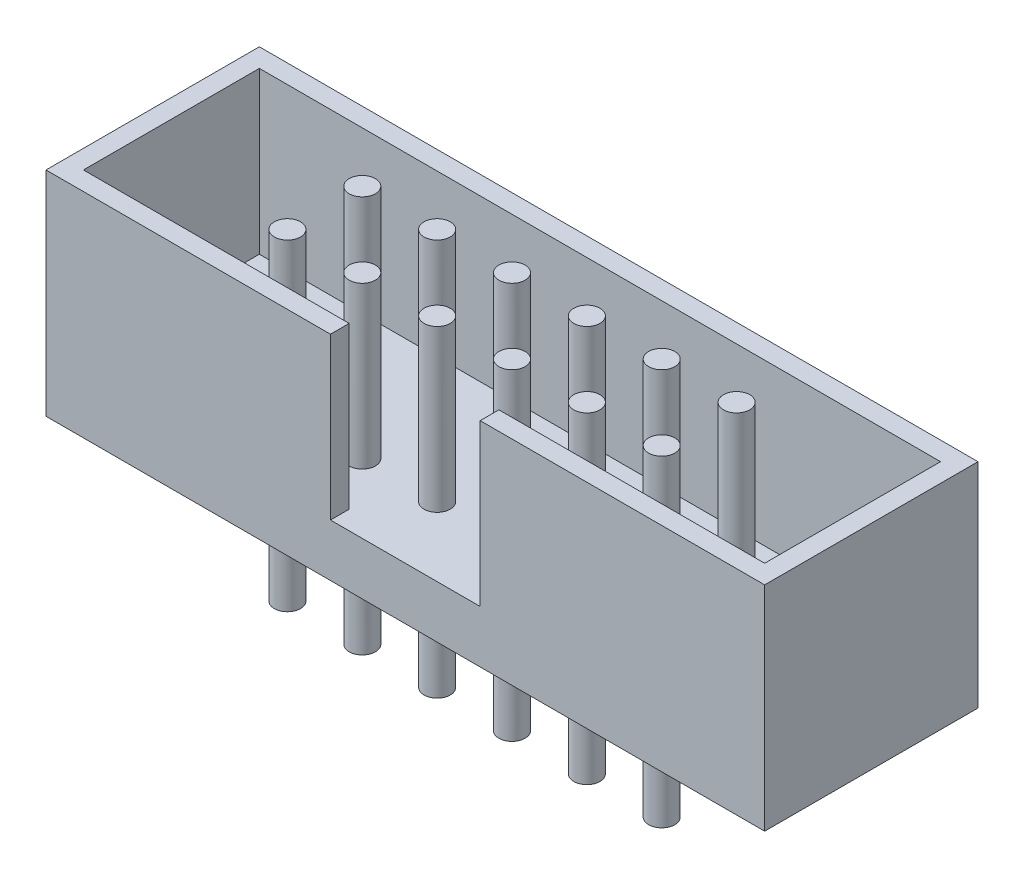
from build123d import *

# Parameters (mm, degrees)
SKETCH_1_W                  = 19.2
SKETCH_1_H                  = 5.7
EXTRUDE_1_DEPTH             = 5.7
SKETCH_2_W                  = 18.2
SKETCH_2_H                  = 4.7
CUT_EXTRUDE_1_DEPTH         = 4.3
CUT_EXTRUDE_2_REACH         = 7.7
SKETCH_3_W                  = 4
SKETCH_3_H                  = 4.3
SKETCH_4_R                  = 0.35
EXTRUDE_2_DEPTH             = 4.3
PATTERN_LINEAR_1_COUNT      = 6
PATTERN_LINEAR_1_PITCH      = 2
PATTERN_LINEAR_1_COUNT_DIR2 = 2
PATTERN_LINEAR_1_PITCH_DIR2 = 2


with BuildPart() as part:
    # 草图1 → 凸台-拉伸1 (new body)
    with BuildSketch(Plane(origin=(0, 0, 0), x_dir=(1, 0, 0), z_dir=(0, 1, 0))):
        with Locations((9.6, 2.85)):
            Rectangle(SKETCH_1_W, SKETCH_1_H)
    extrude(amount=EXTRUDE_1_DEPTH)

    # 草图2 → 切除-拉伸1 (cut)
    with BuildSketch(Plane(origin=(0, 5.7, 0), x_dir=(1, 0, 0), z_dir=(0, 1, 0))):
        with Locations((9.6, 2.85)):
            Rectangle(SKETCH_2_W, SKETCH_2_H)
    extrude(amount=-CUT_EXTRUDE_1_DEPTH, mode=Mode.SUBTRACT)

    # 草图3 → 切除-拉伸2 (cut, up to next)
    with BuildSketch(Plane.XY, mode=Mode.PRIVATE) as cut_extrude_2_sk1:
        with Locations((9.6, 3.55)):
            Rectangle(SKETCH_3_W, SKETCH_3_H)
    cut_extrude_2_tool1 = extrude(cut_extrude_2_sk1.sketch, amount=-CUT_EXTRUDE_2_REACH, mode=Mode.PRIVATE) & part.part
    add(cut_extrude_2_tool1.solids().sort_by_distance((9.6, 3.55, 0))[0], mode=Mode.SUBTRACT)

    # 草图4 → 凸台-拉伸2 (add, symmetric)
    with BuildSketch(Plane(origin=(0, 1.4, 0), x_dir=(1, 0, 0), z_dir=(0, 1, 0))):
        with Locations((4.6, 3.85)):
            Circle(SKETCH_4_R)
    extrude_2 = extrude(amount=EXTRUDE_2_DEPTH, both=True)

    # 阵列(线性)1: Extrude 2 6 × 2
    with Locations(*[(i * PATTERN_LINEAR_1_PITCH, 0, j * PATTERN_LINEAR_1_PITCH_DIR2) for i in range(PATTERN_LINEAR_1_COUNT) for j in range(PATTERN_LINEAR_1_COUNT_DIR2) if (i, j) != (0, 0)]):
        add(extrude_2)


solid = part.part
